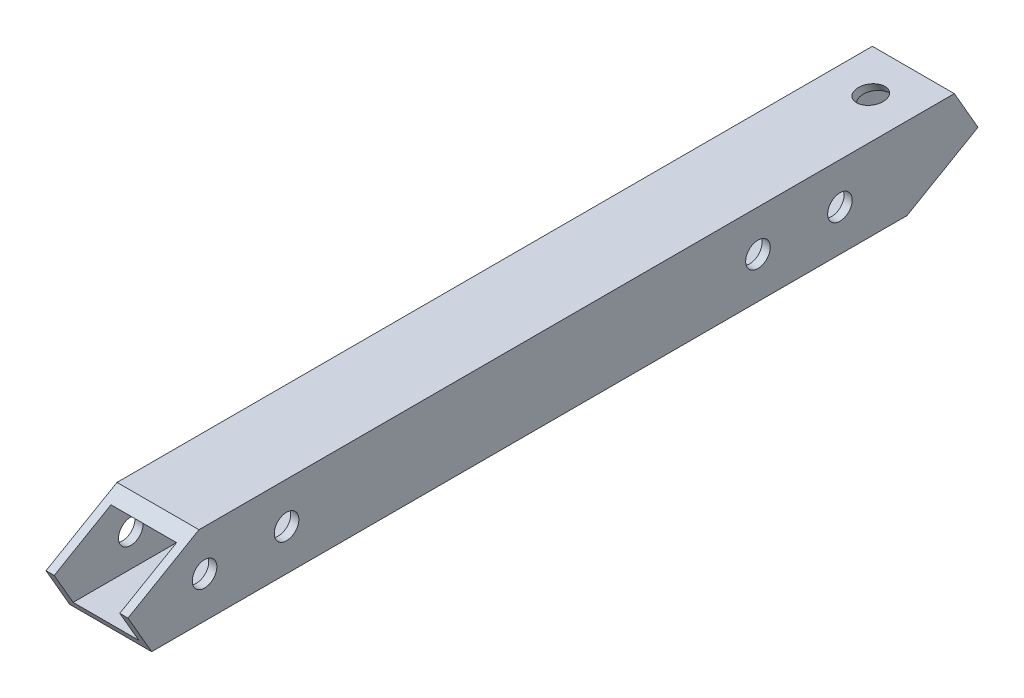
from build123d import *

# Parameters (mm, degrees)
SKETCH_1_W               = 10
SKETCH_1_H               = 10
SKETCH_1_W_2             = 8
SKETCH_1_H_2             = 8
EXTRUDE_1_DEPTH          = 121
SKETCH_2_R               = 1.5
CUT_EXTRUDE_1_DEPTH      = 11
SKETCH_3_R               = 1.5
CUT_EXTRUDE_2_DEPTH      = 51.396370289
CUT_EXTRUDE_2_DEPTH_BACK = 11.103629711


with BuildPart() as part:
    # 草图1 → 拉伸-薄壁1 (new body)
    with BuildSketch(Plane.XY):
        Rectangle(SKETCH_1_W, SKETCH_1_H)
        Rectangle(SKETCH_1_W_2, SKETCH_1_H_2, mode=Mode.SUBTRACT)
    extrude(amount=EXTRUDE_1_DEPTH)

    # 草图2 → 切除-拉伸1 (cut, through all)
    with BuildSketch(Plane(origin=(5, 0, 0), x_dir=(0, 0, -1), z_dir=(1, 0, 0))):
        with Locations((-103, 0)):
            Circle(SKETCH_2_R)
        with Locations((-35.5, 0)):
            Circle(SKETCH_2_R)
        with Locations((-25.5, 0)):
            Circle(SKETCH_2_R)
        with Locations((-93, 0)):
            Circle(SKETCH_2_R)
        Polygon((-112.339745962, 0), (-103.679491924, 5), (-121, 5), (-121, -5), (-109.452994616, -5), align=None)
        Polygon((-8.660254038, 0), (-17.320508076, -5), (0, -5), (0, 5), (-11.547005384, 5), align=None)
    extrude(amount=-CUT_EXTRUDE_1_DEPTH, mode=Mode.SUBTRACT)

    # 草图3 → 切除-拉伸2 (cut, two sides)
    with BuildSketch(Plane(origin=(0, 8.75, 5.051814855), x_dir=(1, 0, 0), z_dir=(0, 0.866025404, 0.5))) as cut_extrude_2_sk:
        with Locations((0, -12)):
            Circle(SKETCH_3_R)
    extrude(amount=CUT_EXTRUDE_2_DEPTH, mode=Mode.SUBTRACT)
    extrude(cut_extrude_2_sk.sketch, amount=-CUT_EXTRUDE_2_DEPTH_BACK, mode=Mode.SUBTRACT)


solid = part.part
